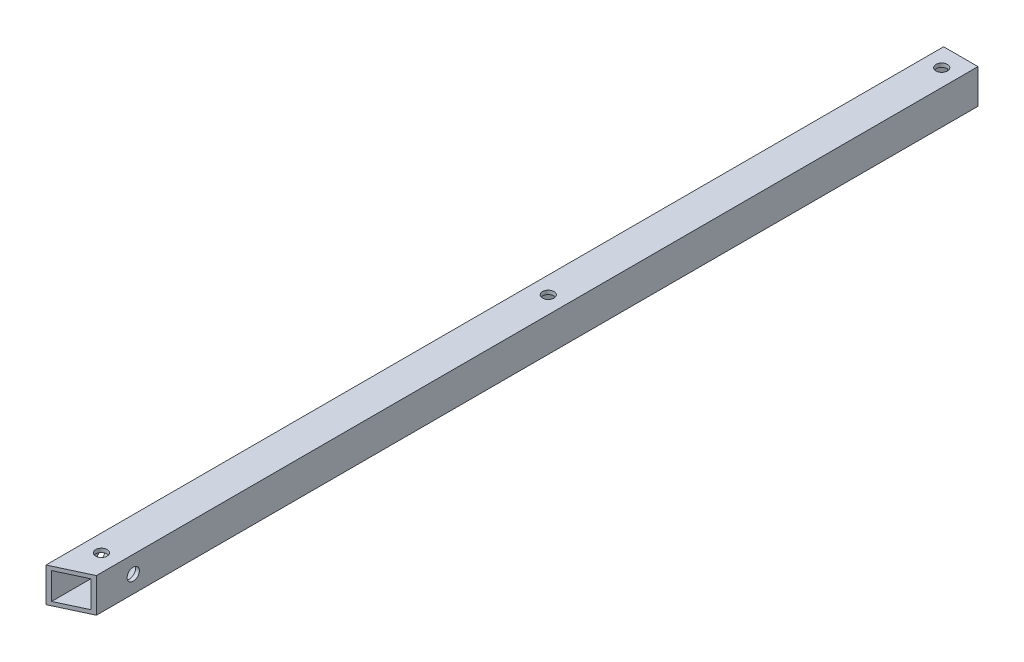
from build123d import *

# Parameters (mm, degrees)
SKETCH_1_W          = 9
SKETCH_1_H          = 9
EXTRUDE_1_DEPTH     = 235
SKETCH_2_W          = 7
SKETCH_2_H          = 7
CUT_EXTRUDE_1_DEPTH = 235
SKETCH_3_R          = 1.5
CUT_EXTRUDE_2_DEPTH = 235
CUT_EXTRUDE_3_DEPTH = 235
SKETCH_5_R          = 1.6
CUT_EXTRUDE_4_DEPTH = 10


with BuildPart() as part:
    # ｽｹｯﾁ1 → ﾎﾞｽ - 押し出し1 (new body)
    with BuildSketch(Plane.XY):
        Rectangle(SKETCH_1_W, SKETCH_1_H)
    extrude(amount=EXTRUDE_1_DEPTH)

    # ｽｹｯﾁ2 → ｶｯﾄ - 押し出し1 (cut)
    with BuildSketch(Plane.XY.offset(235)):
        Rectangle(SKETCH_2_W, SKETCH_2_H)
    extrude(amount=-CUT_EXTRUDE_1_DEPTH, mode=Mode.SUBTRACT)

    # ｽｹｯﾁ3 → ｶｯﾄ - 押し出し2 (cut)
    with BuildSketch(Plane(origin=(0, 4.5, 0), x_dir=(1, 0, 0), z_dir=(0, 1, 0))):
        with Locations((0, -5)):
            Circle(SKETCH_3_R)
        with Locations((0, -108)):
            Circle(SKETCH_3_R)
        with Locations((0, -225)):
            Circle(SKETCH_3_R)
    extrude(amount=-CUT_EXTRUDE_2_DEPTH, mode=Mode.SUBTRACT)

    # ｽｹｯﾁ4 → ｶｯﾄ - 押し出し3 (cut)
    with BuildSketch(Plane(origin=(0, 4.5, 0), x_dir=(1, 0, 0), z_dir=(0, 1, 0))):
        Polygon((4.5, -235), (-4.5, -235), (5.898758527, -230.150979263), align=None)
    extrude(amount=-CUT_EXTRUDE_3_DEPTH, mode=Mode.SUBTRACT)

    # ｽｹｯﾁ5 → ｶｯﾄ - 押し出し4 (cut)
    with BuildSketch(Plane(origin=(4.5, 0, 0), x_dir=(0, 0, -1), z_dir=(1, 0, 0))):
        with Locations((-221.153231077, 0)):
            Circle(SKETCH_5_R)
    extrude(amount=-CUT_EXTRUDE_4_DEPTH, mode=Mode.SUBTRACT)


solid = part.part
